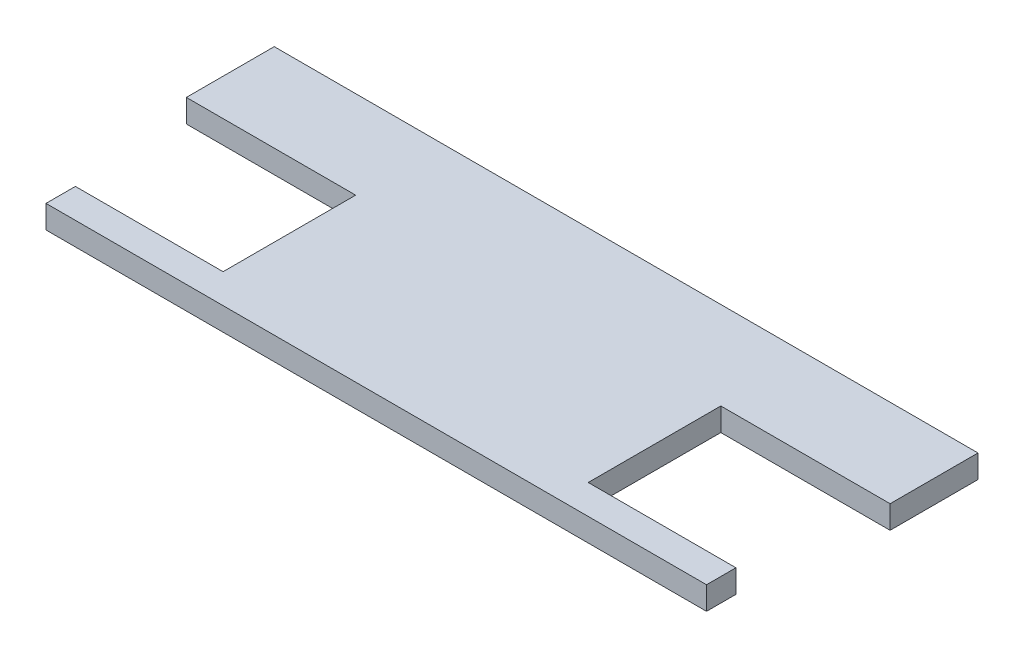
from build123d import *

# Parameters (mm, degrees)
SKETCH1_W         = 48.84
SKETCH1_H         = 17.34
MAIN_SQUARE_DEPTH = 1.6
SKETCH2_W         = 1.5
SKETCH2_H         = 2.04
SERVO_HOLES_DEPTH = 1.6


with BuildPart() as part:
    # Sketch1 → main square (new body)
    with BuildSketch(Plane(origin=(0, 0, 0), x_dir=(1, 0, 0), z_dir=(0, 1, 0))):
        with Locations((24.42, 8.67)):
            Rectangle(SKETCH1_W, SKETCH1_H)
    extrude(amount=MAIN_SQUARE_DEPTH)

    # Sketch2 → servo holes (cut)
    with BuildSketch(Plane(origin=(0, 1.6, 0), x_dir=(1, 0, 0), z_dir=(0, 1, 0))):
        Polygon((11.75, 11.24), (0, 11.24), (0, 2.04), (1.5, 2.04), (11.75, 2.04), align=None)
        with Locations((0.75, 1.02)):
            Rectangle(SKETCH2_W, SKETCH2_H)
    servo_holes = extrude(amount=-SERVO_HOLES_DEPTH, mode=Mode.SUBTRACT)

    # Mirror1: servo holes across plane
    add(servo_holes.mirror(Plane.ZY.offset(-24.42)), mode=Mode.SUBTRACT)


solid = part.part
